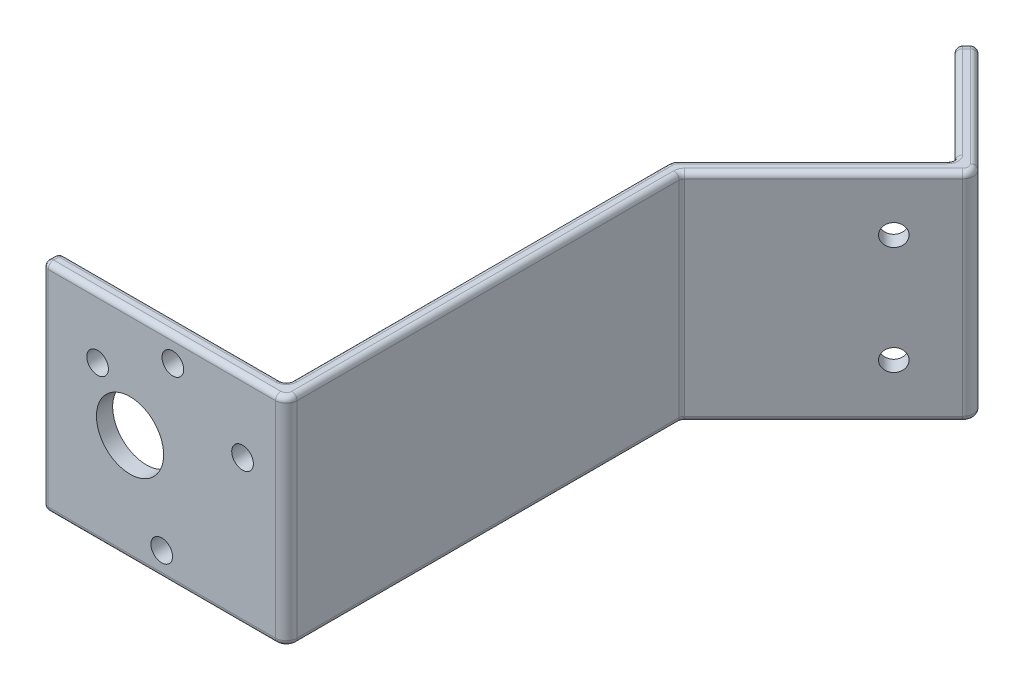
from build123d import *

# Parameters (mm, degrees)
FIXEDMOTOR_R        = 6.207042780583919
FIXEDMOTOR_R_2      = 2.0000000000000004
FIXEDMOTOR_R_3      = 2
FIXEDMOTOR_R_4      = 1.9999999999999996
FIXEDMOTOR_R_5      = 2.0000000000000013
BOSS_EXTRUDE1_DEPTH = 3
BOSS_EXTRUDE2_DEPTH = 3
FILLET2_R           = 1
FILLET3_R           = 2
FILLET4_R           = 1
FILLET5_R           = 1
CUT_EXTRUDE1_DEPTH  = 40
BOSS_EXTRUDE3_DEPTH = 3
CUT_EXTRUDE2_DEPTH  = 40
FILLET6_R           = 2
FILLET7_R           = 1
BOSS_EXTRUDE4_DEPTH = 3
FILLET8_R           = 2
FILLET9_R           = 1
SKETCH9_R           = 2.000000000000003
SKETCH9_R_2         = 2.0000000000000027
CUT_EXTRUDE3_DEPTH  = 3
FILLET10_R          = 2
FILLET11_R          = 2
FILLET15_R          = 1
SKETCH11_R          = 1.9999999999999962
CUT_EXTRUDE4_DEPTH  = 3


with BuildPart() as part:
    # FixedMotor → Boss-Extrude1 (new body)
    with BuildSketch(Plane.XY):
        Polygon((19.000000000955392, 19.999999999092385), (18.99999999904462, -20.000000000907605), (-23.000000000955385, -19.999999998901302), (-23, 1.09869677e-09), (-22.99999999904461, 20.000000001098698), align=None)
        with Locations((-6.884060715651985, 3.2884703e-10)):
            Circle(FIXEDMOTOR_R, mode=Mode.SUBTRACT)
        with Locations((-1.0290674932644954, -15.465801631157241)):
            Circle(FIXEDMOTOR_R_2, mode=Mode.SUBTRACT)
        with Locations((-12.879243355840744, 8.624099406954452)):
            Circle(FIXEDMOTOR_R_3, mode=Mode.SUBTRACT)
        with Locations((13.908310849105225, 6.841702224202803)):
            Circle(FIXEDMOTOR_R_4, mode=Mode.SUBTRACT)
        with Locations((1.0290674932644954, 15.465801631157241)):
            Circle(FIXEDMOTOR_R_5, mode=Mode.SUBTRACT)
    extrude(amount=BOSS_EXTRUDE1_DEPTH)

    # Sketch2 → Boss-Extrude2 (add)
    with BuildSketch(Plane(origin=(19.000000000000007, -9.0761747e-10, 0), x_dir=(0, 0, -1), z_dir=(1.0, -4.776925383032094e-11, 0))):
        Polygon((0, 20), (70, 20), (70, -19.999999999999993), (0, -19.99999999999999), (-3, -19.99999999999999), (-3, 20), align=None)
    extrude(amount=BOSS_EXTRUDE2_DEPTH)

    # Fillet2
    fillet2_edges = [part.edges().sort_by_distance(p)[0] for p in [
        (19.000000000000007, -9.0760821e-10, 0),
    ]]
    fillet(fillet2_edges, radius=FILLET2_R)

    # Fillet3
    fillet3_edges = [part.edges().sort_by_distance(p)[0] for p in [
        (22.000000000000007, -1.05092168e-09, 3),
    ]]
    fillet(fillet3_edges, radius=FILLET3_R)

    # Fillet4
    fillet4_edges = [part.edges().sort_by_distance(p)[0] for p in [
        (-23, 1.09869802e-09, 3),
    ]]
    fillet(fillet4_edges, radius=FILLET4_R)

    # Fillet5
    fillet5_edges = [part.edges().sort_by_distance(p)[0] for p in [
        (-23, 1.09869802e-09, 0),
    ]]
    fillet(fillet5_edges, radius=FILLET5_R)

    # Sketch5 → Cut-Extrude1 (cut)
    with BuildSketch(Plane.XZ.offset(19.999999999999993)):
        Polygon((22.000000000000004, -70), (19.000000000000004, -67), (19.000000000000004, -70), align=None)
    extrude(amount=-CUT_EXTRUDE1_DEPTH, mode=Mode.SUBTRACT)

    # Sketch6 → Boss-Extrude3 (add)
    with BuildSketch(Plane(origin=(-23.99999999999999, 1.14645595e-09, -23.999999999999964), x_dir=(-0.7071067811865471, 3.377778224099027e-11, 0.7071067811865479), z_dir=(-0.7071067811865479, 3.3777782240990306e-11, -0.7071067811865471))):
        Polygon((-65.05382386916239, -19.999999999999993), (-65.05382386916239, 20.000000000000007), (-100.8111831820431, 20.000000000000007), (-100.8111831820431, -20.000000000000004), align=None)
        Polygon((-65.05382386916239, 20.00000000000001), (-65.05382386916239, -19.99999999999999), (-60.81118318204311, -20), (-60.81118318204311, 20.000000000000007), align=None)
    extrude(amount=BOSS_EXTRUDE3_DEPTH)

    # Sketch7 → Cut-Extrude2 (cut)
    with BuildSketch(Plane(origin=(9.5538656e-10, 20.000000000000004, 0), x_dir=(1.0, -4.776932817561277e-11, 0), z_dir=(4.776932817561277e-11, 1.0, 0))):
        Polygon((18.999999999999996, 67), (18.999999999999996, 71.2426406871193), (16.878679656440344, 69.12132034355965), align=None)
    extrude(amount=-CUT_EXTRUDE2_DEPTH, mode=Mode.SUBTRACT)

    # Fillet6
    fillet6_edges = [part.edges().sort_by_distance(p)[0] for p in [
        (18.999999999999996, -9.0761532e-10, -71.2426406871193),
    ]]
    fillet(fillet6_edges, radius=FILLET6_R)

    # Fillet7
    fillet7_edges = [part.edges().sort_by_distance(p)[0] for p in [
        (22.000000000000007, -1.05092168e-09, -70),
    ]]
    fillet(fillet7_edges, radius=FILLET7_R)

    # Sketch8 → Boss-Extrude4 (add)
    with BuildSketch(Plane(origin=(71.28427124746187, -3.40515935e-09, -71.28427124746194), x_dir=(-0.7071067811865479, -3.3777595325221335e-11, -0.7071067811865471), z_dir=(0.7071067811865471, -3.377759532522137e-11, -0.7071067811865479))):
        Polygon((33.94112549560315, 20.0000000022929), (63.94112549560316, 20.0000000022929), (63.94112549560316, -19.99999999770711), (33.94112549830536, -19.99999999770711), align=None)
    extrude(amount=BOSS_EXTRUDE4_DEPTH)

    # Fillet8
    fillet8_edges = [part.edges().sort_by_distance(p)[0] for p in [
        (49.40559159102152, -2.3600452e-09, -97.40559159102156),
    ]]
    fillet(fillet8_edges, radius=FILLET8_R)

    # Fillet9
    fillet9_edges = [part.edges().sort_by_distance(p)[0] for p in [
        (45.16295090390224, -2.15738535e-09, -97.40559159102155),
    ]]
    fillet(fillet9_edges, radius=FILLET9_R)

    # Sketch9 → Cut-Extrude3 (cut)
    with BuildSketch(Plane(origin=(73.40559159102153, -3.50649214e-09, -73.4055915910216), x_dir=(-0.7071067811865479, -3.3777840652168006e-11, -0.7071067811865472), z_dir=(0.7071067811865472, -3.377784065216806e-11, -0.7071067811865479))):
        with Locations((53.94112549560317, 0)):
            Circle(SKETCH9_R)
        with Locations((43.94112549560317, 10)):
            Circle(SKETCH9_R_2)
        with Locations((43.94112549560317, -10)):
            Circle(SKETCH9_R_2)
    extrude(amount=-CUT_EXTRUDE3_DEPTH, mode=Mode.SUBTRACT)

    # Fillet10
    fillet10_edges = [part.edges().sort_by_distance(p)[0] for p in [
        (27.131727984600627, 19.9999999966773, -117.55813485483814),
    ]]
    fillet(fillet10_edges, radius=FILLET10_R)

    # Fillet11
    fillet11_edges = [part.edges().sort_by_distance(p)[0] for p in [
        (27.131727984600627, -20.00000000332271, -117.55813485292741),
    ]]
    fillet(fillet11_edges, radius=FILLET11_R)

    # Fillet15
    fillet15_edges = [part.edges().sort_by_distance(p)[0] for p in [
        (32.02081528112668, 19.999999998470404, -84.2634559672906),
        (32.02081527921592, -20.000000001529603, -84.2634559672906),
        (19.00000000095539, 19.99999999909238, -35.70710678118655),
        (19.15224093593281, 19.999999999085112, -71.17958042710328),
        (19.152240934022036, -20.000000000914874, -71.17958042710328),
        (22.000000000955392, 19.999999998949075, -34.292893218813454),
        (34.78858223218229, -20.000000001661814, -82.78858223313767),
        (34.788582234093056, 19.999999998338193, -82.78858223313767),
        (22.076120468444106, 19.99999999894544, -69.96846986999199),
        (22.076120466533336, -20.00000000105455, -69.968469869992),
        (38.79898987322329, -20.000000002866717, -108.01219330786441),
        (48.57716446531997, -20.00000000245559, -97.40559159102156),
        (48.577164467230716, 19.999999997544418, -97.40559159102156),
        (35.9705627484771, -20.000000002799162, -106.5979797454913),
        (44.74873734248451, 19.999999997862385, -97.40559159102156),
        (44.74873734057375, -20.0000000021376, -97.40559159102156),
        (38.79898987417868, 19.999999997133294, -108.01219330881977),
        (35.970562749432474, 19.99999999720085, -106.59797974644667),
        (26.485281375193907, 19.414213559120846, -116.08326112065726),
        (28.60660171875356, 19.414213559019515, -118.20458146421691),
        (26.071067812820807, -3.27204382e-09, -116.49747468210296),
        (28.192388156380453, -3.37337661e-09, -118.6187950256626),
        (26.485281375193892, -19.41421356562536, -116.08326111880247),
        (28.606601718753545, -19.41421356572669, -118.20458146236213),
        (18.999999999044615, -20.00000000090761, -35.70710678118655),
        (18.707106780231165, -20.000000000893618, -0.2928932188134521),
        (18.70710678214194, 19.999999999106375, -0.2928932188134509),
        (21.999999999044622, -20.000000001050918, -34.292893218813454),
        (21.414213561417718, -20.00000000102293, 2.414213562373094),
        (21.414213563328484, 19.999999998977056, 2.4142135623730967),
        (-23.000000000955385, -19.999999998901302, 1.5),
        (-22.99999999904461, 20.000000001098698, 1.5),
        (-0.9999999990446042, 20.00000000004777, 3),
        (-22.707106780231157, 20.000000001084707, 2.7071067811865466),
        (-1.0000000009553816, -19.999999999952223, 3),
        (-22.707106782141928, -19.999999998915293, 2.707106781186548),
        (-1.9999999990446113, 20.00000000009554, 0),
        (-2.000000000955385, -19.999999999904453, 0),
        (-22.707106780231157, 20.000000001084707, 0.2928932188134523),
        (-22.707106782141935, -19.999999998915293, 0.29289321881345365),
    ]]
    fillet(fillet15_edges, radius=FILLET15_R)

    # Sketch11 → Cut-Extrude4 (cut)
    with BuildSketch(Plane(origin=(-26.121320343559653, 1.24778636e-09, -26.121320343559624), x_dir=(-0.7071067811865472, 3.377767510137627e-11, 0.7071067811865478), z_dir=(-0.7071067811865478, 3.37776751013763e-11, -0.7071067811865472))):
        with Locations((-92.81118318204305, 10)):
            Circle(SKETCH11_R)
        with Locations((-92.81118318204305, -10)):
            Circle(SKETCH11_R)
    extrude(amount=-CUT_EXTRUDE4_DEPTH, mode=Mode.SUBTRACT)


solid = part.part
